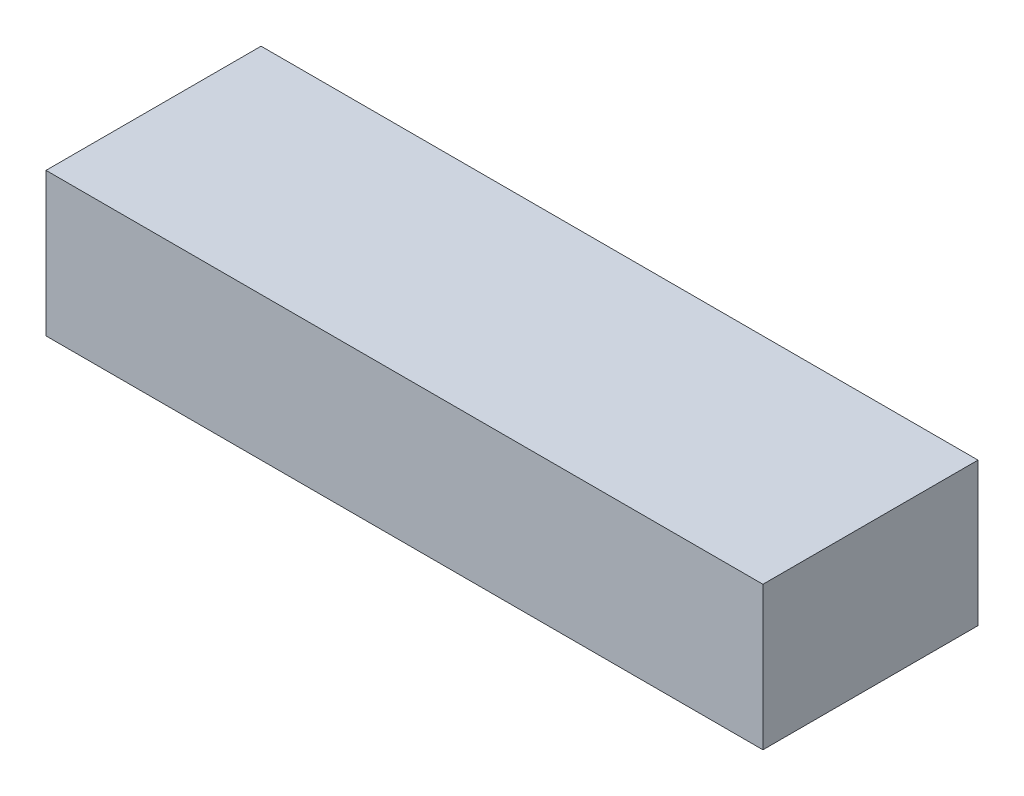
from build123d import *

# Parameters (mm, degrees)
SKETCH1_W      = 127
SKETCH1_H      = 38.1
EXTRUDE1_DEPTH = 25.4


with BuildPart() as part:
    # Sketch1 → Extrude1 (new body)
    with BuildSketch(Plane(origin=(0, 0, 0), x_dir=(1, 0, 0), z_dir=(0, 1, 0))):
        Rectangle(SKETCH1_W, SKETCH1_H)
    extrude(amount=EXTRUDE1_DEPTH)


solid = part.part
